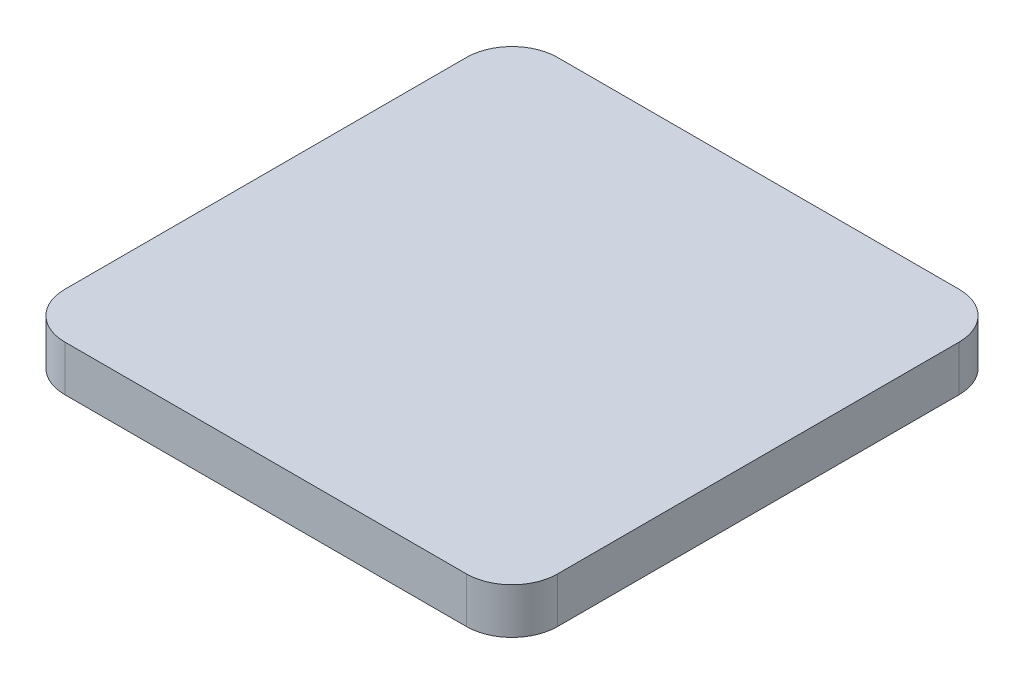
from build123d import *

# Parameters (mm, degrees)
SKETCH_1_W      = 54
SKETCH_1_H      = 54
EXTRUDE_2_DEPTH = 5
FILLET_1_R      = 5


with BuildPart() as part:
    # 草图1 → 凸台-拉伸2 (new body)
    with BuildSketch(Plane(origin=(0, 0, 0), x_dir=(1, 0, 0), z_dir=(0, 1, 0))):
        Rectangle(SKETCH_1_W, SKETCH_1_H)
    extrude(amount=EXTRUDE_2_DEPTH)

    # 圆角1
    fillet_1_edges = [part.edges().sort_by_distance(p)[0] for p in [
        (27, 2.5, 27),
        (-27, 2.5, 27),
        (-27, 2.5, -27),
        (27, 2.5, -27),
    ]]
    fillet(fillet_1_edges, radius=FILLET_1_R)


solid = part.part
